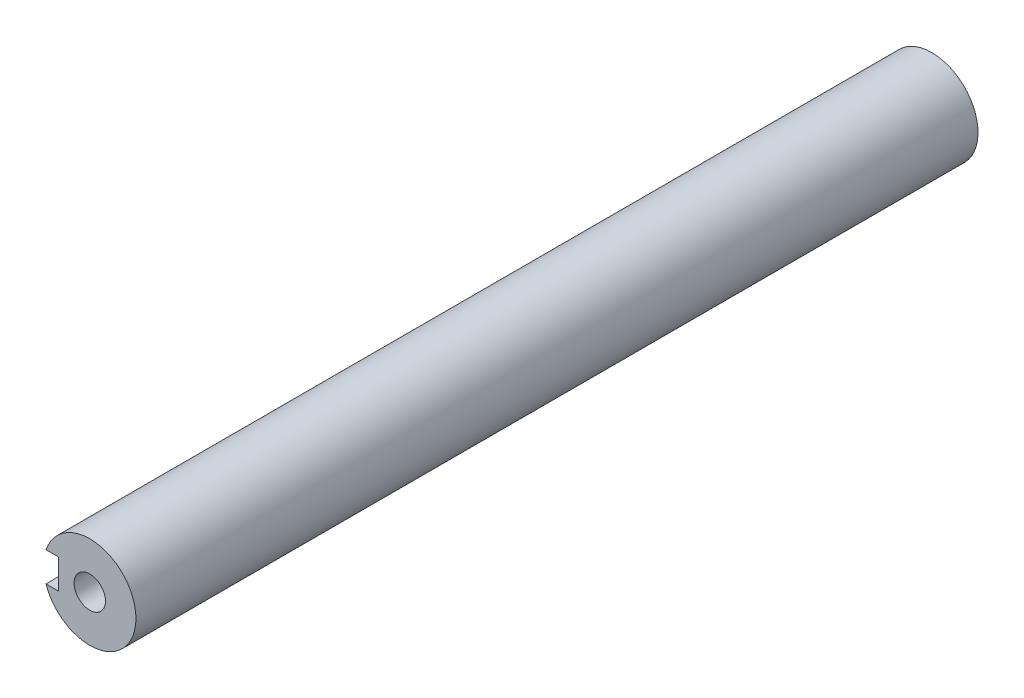
from build123d import *

# Parameters (mm, degrees)
EXTRUDE_START          = -1.5
SKETCH_1_R             = 12.5
EXTRUDE_1_DEPTH        = 227.9
HOLE_WIZARD_M101_D     = 8.5
HOLE_WIZARD_M101_DEPTH = 30
HOLE_WIZARD_M101_TIP   = 2.553657631
HOLE_WIZARD_M102_D     = 8.5
HOLE_WIZARD_M102_DEPTH = 32.5
HOLE_WIZARD_M102_TIP   = 2.553657631
SKETCH_6_W             = 8
SKETCH_6_H             = 8
CUT_EXTRUDE_1_DEPTH    = 30


with BuildPart() as part:
    # Эскиз1 → Бобышка-Вытянуть1 (new body)
    with BuildSketch(Plane.XY.offset(EXTRUDE_START)):
        with Locations((0.192463074, -155.807573628)):
            Circle(SKETCH_1_R)
    extrude(amount=-EXTRUDE_1_DEPTH)

    # Отверстие обработанное метчиком M101
    with Locations(Plane.XY.offset(-1.5)):
        with Locations((0.192463074, -155.807573628)):
            Hole(HOLE_WIZARD_M101_D / 2, depth=HOLE_WIZARD_M101_DEPTH)
            with Locations((0, 0, -(HOLE_WIZARD_M101_DEPTH + HOLE_WIZARD_M101_TIP / 2))):  # 118° drill point
                Cone(0, HOLE_WIZARD_M101_D / 2, HOLE_WIZARD_M101_TIP, mode=Mode.SUBTRACT)

    # Отверстие обработанное метчиком M102
    with Locations(Plane(origin=(0, 0, -229.4), x_dir=(-1, 0, 0), z_dir=(0, 0, -1))):
        with Locations((-0.192463074, -155.807573628)):
            Hole(HOLE_WIZARD_M102_D / 2, depth=HOLE_WIZARD_M102_DEPTH)
            with Locations((0, 0, -(HOLE_WIZARD_M102_DEPTH + HOLE_WIZARD_M102_TIP / 2))):  # 118° drill point
                Cone(0, HOLE_WIZARD_M102_D / 2, HOLE_WIZARD_M102_TIP, mode=Mode.SUBTRACT)

    # Эскиз6 → Вырез-Вытянуть1 (cut)
    with BuildSketch(Plane.XY.offset(-1.5)):
        with Locations((-12.307536926, -155.807573628)):
            Rectangle(SKETCH_6_W, SKETCH_6_H)
    extrude(amount=-CUT_EXTRUDE_1_DEPTH, mode=Mode.SUBTRACT)


solid = part.part
